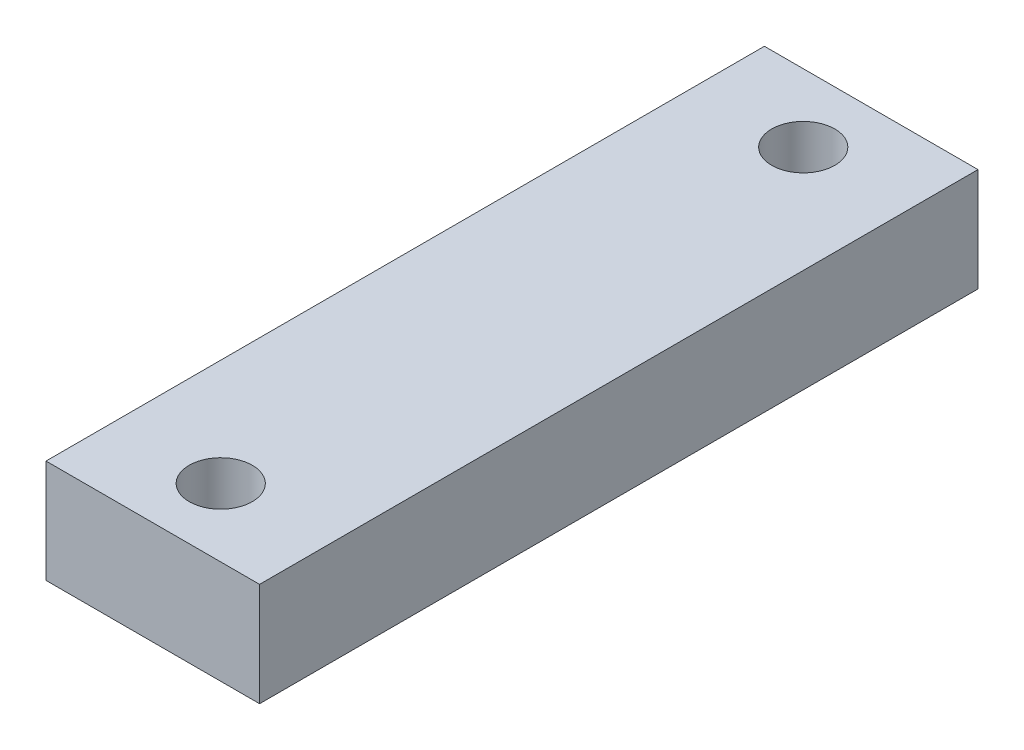
from build123d import *

# Parameters (mm, degrees)
CROQUIS1_W              = 22
CROQUIS1_H              = 10.65
SALIENTE_EXTRUIR1_DEPTH = 74
CORTAR_EXTRUIR1_REACH   = 12.65
CROQUIS2_R              = 3.25


with BuildPart() as part:
    # Croquis1 → Saliente-Extruir1 (new body)
    with BuildSketch(Plane.XY):
        with Locations((18, 0)):
            Rectangle(CROQUIS1_W, CROQUIS1_H)
    extrude(amount=SALIENTE_EXTRUIR1_DEPTH)

    # Croquis2 → Cortar-Extruir1 (cut, up to next)
    with BuildSketch(Plane(origin=(0, 5.325, 0), x_dir=(1, 0, 0), z_dir=(0, 1, 0)), mode=Mode.PRIVATE) as cortar_extruir1_sk1:
        with Locations((18, -7)):
            Circle(CROQUIS2_R)
    cortar_extruir1_tool1 = extrude(cortar_extruir1_sk1.sketch, amount=-CORTAR_EXTRUIR1_REACH, mode=Mode.PRIVATE) & part.part
    add(cortar_extruir1_tool1.solids().sort_by_distance((18, 5.325, 7))[0], mode=Mode.SUBTRACT)
    # Croquis2 → Cortar-Extruir1 (cut, up to next)
    with BuildSketch(Plane(origin=(0, 5.325, 0), x_dir=(1, 0, 0), z_dir=(0, 1, 0)), mode=Mode.PRIVATE) as cortar_extruir1_sk2:
        with Locations((18, -67)):
            Circle(CROQUIS2_R)
    cortar_extruir1_tool2 = extrude(cortar_extruir1_sk2.sketch, amount=-CORTAR_EXTRUIR1_REACH, mode=Mode.PRIVATE) & part.part
    add(cortar_extruir1_tool2.solids().sort_by_distance((18, 5.325, 67))[0], mode=Mode.SUBTRACT)


solid = part.part
